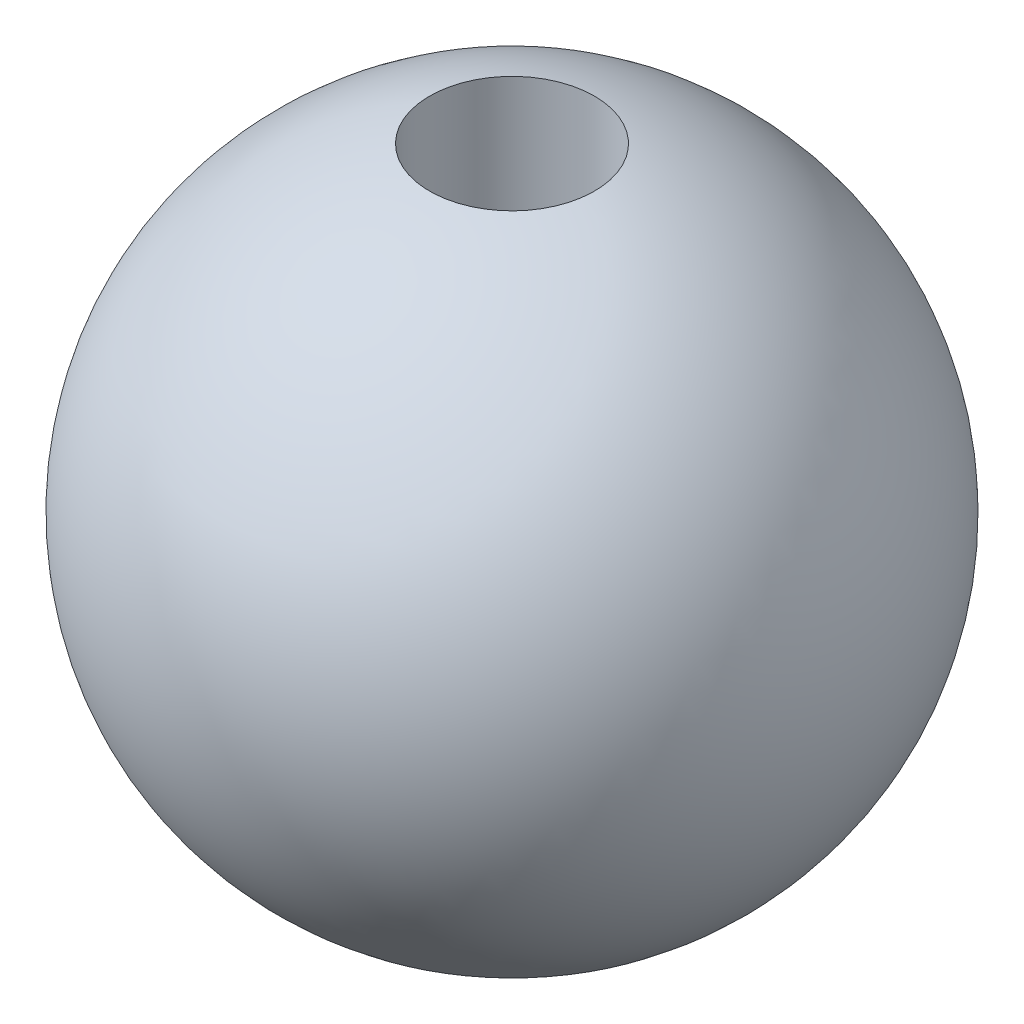
from build123d import *

# Parameters (mm, degrees)
SKETCH2_R          = 1.5
CUT_EXTRUDE1_DEPTH = 7


with BuildPart() as part:
    # Sketch1 one side → Revolve3 (revolve)
    with BuildSketch(Plane(origin=(0, 0, 0), x_dir=(1, 0, 0), z_dir=(0, 1, 0))):
        with BuildLine():
            ThreePointArc((0, -6), (4.242640687, -4.242640687), (6, 0))
            ThreePointArc((6, 0), (4.242640687, 4.242640687), (0, 6))
            Line((0, 6), (0, -6))
        make_face()
    revolve(axis=Axis((0, 0, -11.594924131), (0, 0, 1)))

    # Sketch2 → Cut-Extrude1 (cut, through all)
    with BuildSketch(Plane(origin=(0, 0, 0), x_dir=(1, 0, 0), z_dir=(0, 1, 0))):
        Circle(SKETCH2_R)
    extrude(amount=CUT_EXTRUDE1_DEPTH, mode=Mode.SUBTRACT)


solid = part.part
